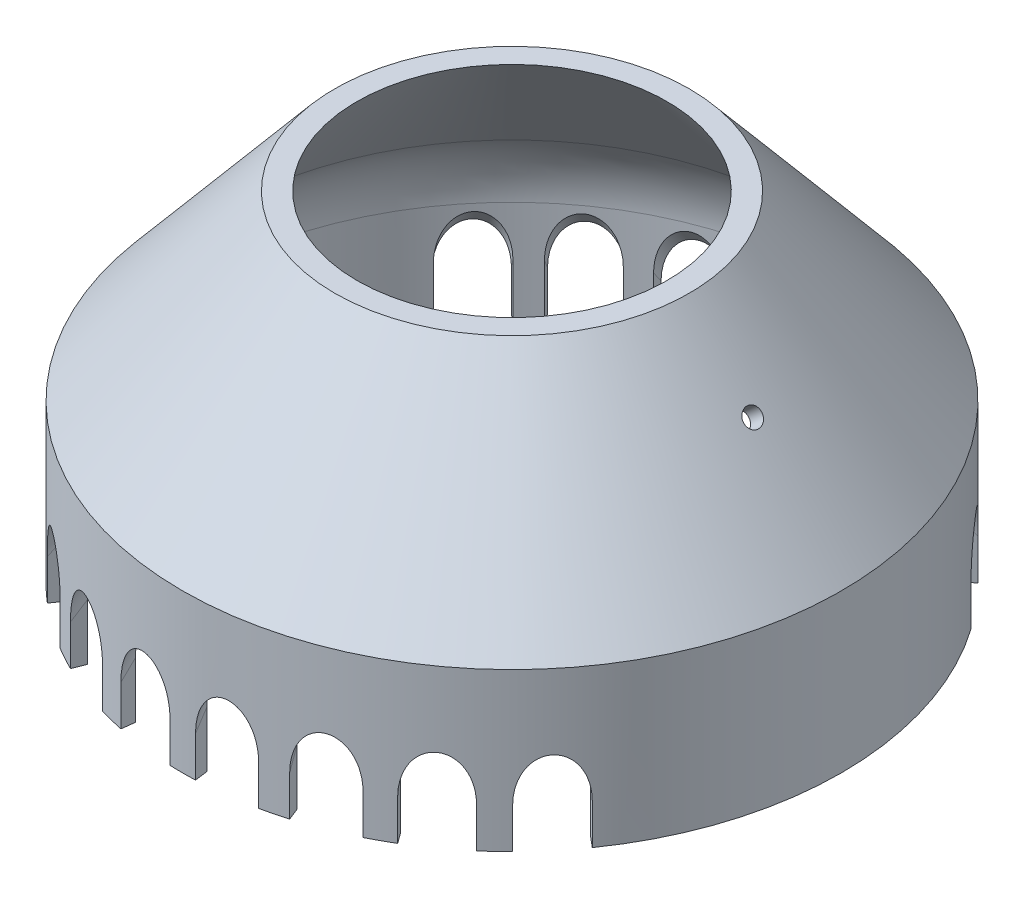
from build123d import *

# Parameters (mm, degrees)
SUPPORT_HOLE_1_REACH             = 61.87
SKETCH4_R                        = 0.80645
SUPPORT_HOLE_1_DIRECTION_2_REACH = 61.87
SUPPORT_START                    = -1.5
SKETCH3_R                        = 0.80645
SUPPORT_HOLE_2_DEPTH             = 1.512368
TURN_TOOL_CHANNEL_REACH          = 56.384
CRVPATTERN2_COUNT                = 8
CRVPATTERN2_ANGLE                = 100
MIRROR1_COPY_1_REACH             = 56.384
MIRROR1_COPY_2_REACH             = 56.384
MIRROR1_COPY_3_REACH             = 56.384
MIRROR1_COPY_4_REACH             = 56.384
MIRROR1_COPY_5_REACH             = 56.384
MIRROR1_COPY_6_REACH             = 56.384
MIRROR1_COPY_7_REACH             = 56.384


with BuildPart() as part:
    # Cone Cross Section → Revolve1 (revolve)
    with BuildSketch(Plane(origin=(0, 0, 0), x_dir=(1, 0, 0), z_dir=(0, 0, -1)), mode=Mode.PRIVATE) as revolve1_sk:
        with BuildLine():
            Line((13.718550028, 0), (25.660444431, 14.231795558))
            ThreePointArc((25.660444431, 14.231795558), (27.396926208, 17.239470221), (28, 20.659671654))
            Line((28, 20.659671654), (28, 30))
            Line((28, 30), (29.149066665, 30))
            Line((29.149066665, 30), (29.149066665, 16.055787897))
            Line((29.149066665, 16.055787897), (15.676660962, 0))
            Line((15.676660962, 0), (13.718550028, 0))
        make_face()
    revolve(revolve1_sk.sketch.rotate(Axis((0, 0, 0), (0, -1, 0)), 90), axis=Axis((0, 0, 0), (0, -1, 0)))

    # Support Hole 1: up to this cone (the profile starts inside it)
    support_hole_1_end = Plane(origin=(0, -7.660444, 0), z_dir=(0, -1, 0)).offset(-26.343160021) * Cone(1e-06, 92.987089283, 110.817696718, align=(Align.CENTER, Align.CENTER, Align.MIN), mode=Mode.PRIVATE)
    # Sketch4 → Support Hole 1 (cut, up to the surface)
    with BuildSketch(Plane(origin=(-8.05037562, 6.755067214, 0), x_dir=(0, 0, 1), z_dir=(-0.766044443118977, 0.6427876096865406, 0)), mode=Mode.PRIVATE) as support_hole_1_sk1:
        with Locations(Location((0, -18.818113981, 0), (0, 0, 220.222277667))):
            Circle(SKETCH4_R)
    support_hole_1_tool1 = extrude(support_hole_1_sk1.sketch, amount=SUPPORT_HOLE_1_REACH, mode=Mode.PRIVATE) & support_hole_1_end
    add(support_hole_1_tool1.solids().sort_by_distance((-20.146426, -7.660444, 0))[0], mode=Mode.SUBTRACT)

    # Support Hole 1 direction 2: up to this cone (the profile starts outside it)
    support_hole_1_direction_2_end = Plane(origin=(0, -7.660444, 0), z_dir=(0, -1, 0)).offset(-24.009574281) * Cone(1e-06, 89.385928187, 106.526000044, align=(Align.CENTER, Align.CENTER, Align.MIN), mode=Mode.PRIVATE)
    # Sketch4 → Support Hole 1 direction 2 (cut, up to the surface)
    with BuildSketch(Plane(origin=(-8.05037562, 6.755067214, 0), x_dir=(0, 0, 1), z_dir=(-0.766044443118977, 0.6427876096865406, 0)), mode=Mode.PRIVATE) as support_hole_1_direction_2_sk1:
        with Locations(Location((0, -18.818113981, 0), (0, 0, 220.222277667))):
            Circle(SKETCH4_R)
    support_hole_1_direction_2_tool1 = extrude(support_hole_1_direction_2_sk1.sketch, amount=-SUPPORT_HOLE_1_DIRECTION_2_REACH, mode=Mode.PRIVATE) - support_hole_1_direction_2_end
    add(support_hole_1_direction_2_tool1.solids().sort_by_distance((-20.146426, -7.660444, 0))[0], mode=Mode.SUBTRACT)


with BuildPart() as support_hole_1_kept_piece:
    # of the separate pieces the step leaves, the one the design keeps (support_hole_1_pieces_kept)
    add(part.part.solids().sort_by_distance((0, 0, 13.718550028))[0])

    # Sketch3 → Support Hole 2 (cut)
    with BuildSketch(Plane(origin=(8.05037562, 6.755067214, 0), x_dir=(0, 0, 1), z_dir=(-0.766044443118977, -0.6427876096865406, 0)).offset(SUPPORT_START)):
        with Locations(Location((0, -18.818113981, 0), (0, 0, 235.38390566))):
            Circle(SKETCH3_R)
    extrude(amount=SUPPORT_HOLE_2_DEPTH, mode=Mode.SUBTRACT)

    # Sketch5 → Turn Tool Channel (cut, up to next)
    with BuildSketch(Plane(origin=(7.788900643, -12.117378316, 6.535663657), x_dir=(0.8703668320896414, 0.43338422313512226, -0.2337513480940991), z_dir=(-0.4924038765061076, 0.7660444431189767, -0.413175911166533)), mode=Mode.PRIVATE) as turn_tool_channel_sk1:
        with BuildLine():
            Line((1.699455866, -5.569482092), (-1.671674945, -1.876857408))
            Line((-1.671674945, -1.876857408), (2.020949739, 1.494273403))
            Line((2.020949739, 1.494273403), (5.39208055, -2.198351282))
            ThreePointArc((5.39208055, -2.198351282), (5.231333613, -5.730229029), (1.699455866, -5.569482092))
        make_face()
    turn_tool_channel_tool1 = extrude(turn_tool_channel_sk1.sketch, amount=-TURN_TOOL_CHANNEL_REACH, mode=Mode.PRIVATE) & support_hole_1_kept_piece.part
    turn_tool_channel = turn_tool_channel_tool1.solids().sort_by_distance((9.997192, -9.69849, 8.38864))[0]
    add(turn_tool_channel, mode=Mode.SUBTRACT)

    # CrvPattern2: Turn Tool Channel ×8 about axis
    crvpattern2_axis = Axis((0, -10.826005784, 0), (0, -1, 0))
    for i in range(1, CRVPATTERN2_COUNT):
        add(turn_tool_channel.rotate(crvpattern2_axis, i * CRVPATTERN2_ANGLE / (CRVPATTERN2_COUNT - 1)), mode=Mode.SUBTRACT)

    # Mirror1: Turn Tool Channel across plane
    add(turn_tool_channel.mirror(Plane.XY), mode=Mode.SUBTRACT)

    # Mirror1 copy 1 sketch → Mirror1 copy 1 (cut, up to next)
    with BuildSketch(Plane(origin=(5.935323342, -12.117378316, -8.255532054), x_dir=(0.9011326020275271, 0.43338422313512226, 0.011753667541032992), z_dir=(-0.37522319974544693, 0.7660444431189767, 0.5219036899077504)), mode=Mode.PRIVATE) as mirror1_copy_1_sk1:
        with BuildLine():
            Line((1.699455866, 5.569482092), (-1.671674945, 1.876857408))
            Line((-1.671674945, 1.876857408), (2.020949739, -1.494273403))
            Line((2.020949739, -1.494273403), (5.39208055, 2.198351282))
            ThreePointArc((5.39208055, 2.198351282), (5.231333613, 5.730229029), (1.699455866, 5.569482092))
        make_face()
    mirror1_copy_1_tool1 = extrude(mirror1_copy_1_sk1.sketch, amount=-MIRROR1_COPY_1_REACH, mode=Mode.PRIVATE) & support_hole_1_kept_piece.part
    add(mirror1_copy_1_tool1.solids().sort_by_distance((7.618092717, -9.69849, -10.596121568))[0], mode=Mode.SUBTRACT)

    # Mirror1 copy 2 sketch → Mirror1 copy 2 (cut, up to next)
    with BuildSketch(Plane(origin=(3.714673431, -12.117378316, -9.464833541), x_dir=(0.8761674409211258, 0.43338422313512226, -0.21097092360629302), z_dir=(-0.2348366837729102, 0.7660444431189767, 0.5983541118109569)), mode=Mode.PRIVATE) as mirror1_copy_2_sk1:
        with BuildLine():
            Line((1.699455866, 5.569482092), (-1.671674945, 1.876857408))
            Line((-1.671674945, 1.876857408), (2.020949739, -1.494273403))
            Line((2.020949739, -1.494273403), (5.39208055, 2.198351282))
            ThreePointArc((5.39208055, 2.198351282), (5.231333613, 5.730229029), (1.699455866, 5.569482092))
        make_face()
    mirror1_copy_2_tool1 = extrude(mirror1_copy_2_sk1.sketch, amount=-MIRROR1_COPY_2_REACH, mode=Mode.PRIVATE) & support_hole_1_kept_piece.part
    add(mirror1_copy_2_tool1.solids().sort_by_distance((4.767849232, -9.69849, -12.148281468))[0], mode=Mode.SUBTRACT)

    # Mirror1 copy 3 sketch → Mirror1 copy 3 (cut, up to next)
    with BuildSketch(Plane(origin=(1.264287953, -12.117378316, -10.088778352), x_dir=(0.7970153298327136, 0.43338422313512226, -0.42064792778429017), z_dir=(-0.07992659268992885, 0.7660444431189767, 0.637799067847794)), mode=Mode.PRIVATE) as mirror1_copy_3_sk1:
        with BuildLine():
            Line((1.699455866, 5.569482092), (-1.671674945, 1.876857408))
            Line((-1.671674945, 1.876857408), (2.020949739, -1.494273403))
            Line((2.020949739, -1.494273403), (5.39208055, 2.198351282))
            ThreePointArc((5.39208055, 2.198351282), (5.231333613, 5.730229029), (1.699455866, 5.569482092))
        make_face()
    mirror1_copy_3_tool1 = extrude(mirror1_copy_3_sk1.sketch, amount=-MIRROR1_COPY_3_REACH, mode=Mode.PRIVATE) & support_hole_1_kept_piece.part
    add(mirror1_copy_3_tool1.solids().sort_by_distance((1.622736074, -9.69849, -12.949125707))[0], mode=Mode.SUBTRACT)

    # Mirror1 copy 4 sketch → Mirror1 copy 4 (cut, up to next)
    with BuildSketch(Plane(origin=(-1.264287953, -12.117378316, -10.088778352), x_dir=(0.6685714649133934, 0.43338422313512226, -0.6043097810238768), z_dir=(0.07992659268992386, 0.7660444431189767, 0.6377990678477947)), mode=Mode.PRIVATE) as mirror1_copy_4_sk1:
        with BuildLine():
            Line((1.699455866, 5.569482092), (-1.671674945, 1.876857408))
            Line((-1.671674945, 1.876857408), (2.020949739, -1.494273403))
            Line((2.020949739, -1.494273403), (5.39208055, 2.198351282))
            ThreePointArc((5.39208055, 2.198351282), (5.231333613, 5.730229029), (1.699455866, 5.569482092))
        make_face()
    mirror1_copy_4_tool1 = extrude(mirror1_copy_4_sk1.sketch, amount=-MIRROR1_COPY_4_REACH, mode=Mode.PRIVATE) & support_hole_1_kept_piece.part
    add(mirror1_copy_4_tool1.solids().sort_by_distance((-1.622735891, -9.69849, -12.94912573))[0], mode=Mode.SUBTRACT)

    # Mirror1 copy 5 sketch → Mirror1 copy 5 (cut, up to next)
    with BuildSketch(Plane(origin=(-3.714673431, -12.117378316, -9.464833541), x_dir=(0.4987795119042271, 0.43338422313512226, -0.7505978374883235), z_dir=(0.23483668377290537, 0.7660444431189767, 0.5983541118109588)), mode=Mode.PRIVATE) as mirror1_copy_5_sk1:
        with BuildLine():
            Line((1.699455866, 5.569482092), (-1.671674945, 1.876857408))
            Line((-1.671674945, 1.876857408), (2.020949739, -1.494273403))
            Line((2.020949739, -1.494273403), (5.39208055, 2.198351282))
            ThreePointArc((5.39208055, 2.198351282), (5.231333613, 5.730229029), (1.699455866, 5.569482092))
        make_face()
    mirror1_copy_5_tool1 = extrude(mirror1_copy_5_sk1.sketch, amount=-MIRROR1_COPY_5_REACH, mode=Mode.PRIVATE) & support_hole_1_kept_piece.part
    add(mirror1_copy_5_tool1.solids().sort_by_distance((-4.767849061, -9.69849, -12.148281535))[0], mode=Mode.SUBTRACT)

    # Mirror1 copy 6 sketch → Mirror1 copy 6 (cut, up to next)
    with BuildSketch(Plane(origin=(-5.935323342, -12.117378316, -8.255532054), x_dir=(0.29814032673223123, 0.43338422313512226, -0.8504648497813211), z_dir=(0.3752231997454428, 0.7660444431189767, 0.5219036899077534)), mode=Mode.PRIVATE) as mirror1_copy_6_sk1:
        with BuildLine():
            Line((1.699455866, 5.569482092), (-1.671674945, 1.876857408))
            Line((-1.671674945, 1.876857408), (2.020949739, -1.494273403))
            Line((2.020949739, -1.494273403), (5.39208055, 2.198351282))
            ThreePointArc((5.39208055, 2.198351282), (5.231333613, 5.730229029), (1.699455866, 5.569482092))
        make_face()
    mirror1_copy_6_tool1 = extrude(mirror1_copy_6_sk1.sketch, amount=-MIRROR1_COPY_6_REACH, mode=Mode.PRIVATE) & support_hole_1_kept_piece.part
    add(mirror1_copy_6_tool1.solids().sort_by_distance((-7.618092567, -9.69849, -10.596121676))[0], mode=Mode.SUBTRACT)

    # Mirror1 copy 7 sketch → Mirror1 copy 7 (cut, up to next)
    with BuildSketch(Plane(origin=(-7.788900643, -12.117378316, -6.535663657), x_dir=(0.07906252558601568, 0.43338422313512226, -0.8977344998302824), z_dir=(0.4924038765061043, 0.7660444431189767, 0.41317591116653696)), mode=Mode.PRIVATE) as mirror1_copy_7_sk1:
        with BuildLine():
            Line((1.699455866, 5.569482092), (-1.671674945, 1.876857408))
            Line((-1.671674945, 1.876857408), (2.020949739, -1.494273403))
            Line((2.020949739, -1.494273403), (5.39208055, 2.198351282))
            ThreePointArc((5.39208055, 2.198351282), (5.231333613, 5.730229029), (1.699455866, 5.569482092))
        make_face()
    mirror1_copy_7_tool1 = extrude(mirror1_copy_7_sk1.sketch, amount=-MIRROR1_COPY_7_REACH, mode=Mode.PRIVATE) & support_hole_1_kept_piece.part
    add(mirror1_copy_7_tool1.solids().sort_by_distance((-9.997191882, -9.69849, -8.388640141))[0], mode=Mode.SUBTRACT)


solid = support_hole_1_kept_piece.part
